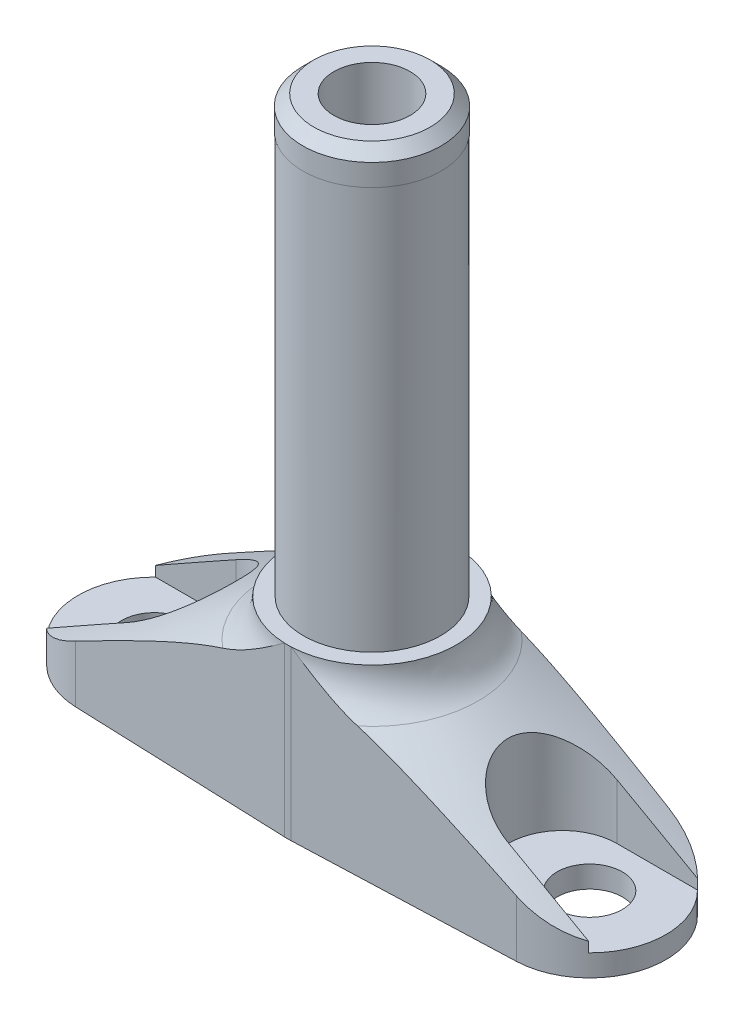
from build123d import *

# Parameters (mm, degrees)
SZKIC1_W                        = 27
SZKIC1_H                        = 25
ZAOKR_GLENIE1_R                 = 4
SZKIC4_R                        = 3
WYTNIJ_WYCI_GNI_CIE3_DEPTH      = 24.0000001
WYTNIJ_WYCI_GNI_CIE3_DEPTH_BACK = 3
WYTNIJ_WYCI_GNI_CIE2_DEPTH      = 24.0000001
SZKIC5_OUTSIDE_W                = 72.072
SZKIC5_OUTSIDE_H                = 72.072
WYTNIJ_WYCI_GNI_CIE4_DEPTH      = 26.0000001
SZKIC8_W                        = 7.75
SZKIC8_H                        = 9.576606241
SZKIC10_R                       = 3.5
WYTNIJ_WYCI_GNI_CIE5_DEPTH      = 56.423393859


with BuildPart() as part:
    # Szkic1 → Obrót1 (revolve)
    with BuildSketch(Plane.XY):
        with Locations((13.5, 12.5)):
            Rectangle(SZKIC1_W, SZKIC1_H)
    revolve(axis=Axis((0, 0, 0), (0, 1, 0)))

    # Szkic2 → Wycięcie-obrót1 (revolve, cut)
    with BuildSketch(Plane.XY):
        Polygon((27, 25), (27, 2), (7.75, 13.113992682), (7.75, 25), align=None)
    revolve(axis=Axis((0, 0, 0), (0, 1, 0)), mode=Mode.SUBTRACT)

    # Zaokrąglenie1
    zaokr_glenie1_edges = [part.edges().sort_by_distance(p)[0] for p in [
        (-7.75, 13.113992682, 0),
    ]]
    fillet(zaokr_glenie1_edges, radius=ZAOKR_GLENIE1_R)

    # Szkic4 → Wytnij-wyciągnięcie3 (cut, two sides)
    with BuildSketch(Plane(origin=(0, 2, 0), x_dir=(1, 0, 0), z_dir=(0, 1, 0))) as wytnij_wyci_gni_cie3_sk:
        with Locations((-20, 0)):
            Circle(SZKIC4_R)
        with Locations((20, 0)):
            Circle(SZKIC4_R)
    extrude(amount=WYTNIJ_WYCI_GNI_CIE3_DEPTH, mode=Mode.SUBTRACT)
    extrude(wytnij_wyci_gni_cie3_sk.sketch, amount=-WYTNIJ_WYCI_GNI_CIE3_DEPTH_BACK, mode=Mode.SUBTRACT)

    # Szkic3 → Wytnij-wyciągnięcie2 (cut, through all)
    with BuildSketch(Plane(origin=(0, 2, 0), x_dir=(1, 0, 0), z_dir=(0, 1, 0))):
        with BuildLine():
            Line((-17.5, 5), (-26.532998323, 5))
            ThreePointArc((-26.532998323, 5), (-27, 0), (-26.532998323, -5))
            Line((-26.532998323, -5), (-17.5, -5))
            ThreePointArc((-17.5, -5), (-12.5, 0), (-17.5, 5))
        make_face()
        with BuildLine():
            Line((17.5, 5), (26.532998323, 5))
            ThreePointArc((26.532998323, 5), (27, 0), (26.532998323, -5))
            Line((26.532998323, -5), (17.5, -5))
            ThreePointArc((17.5, -5), (12.5, 0), (17.5, 5))
        make_face()
    extrude(amount=WYTNIJ_WYCI_GNI_CIE2_DEPTH, mode=Mode.SUBTRACT)

    # Szkic5 outside → Wytnij-wyciągnięcie4 (cut, through all)
    with BuildSketch(Plane.XZ):
        Rectangle(SZKIC5_OUTSIDE_W, SZKIC5_OUTSIDE_H)
        with BuildLine():
            Line((-20.2625, 6.995076393), (-0.290625, 7.744548864))
            ThreePointArc((-0.290625, 7.744548864), (0, 7.75), (0.290625, 7.744548864))
            Line((0.290625, 7.744548864), (20.2625, 6.995076393))
            ThreePointArc((20.2625, 6.995076393), (27, 0), (20.2625, -6.995076393))
            Line((20.2625, -6.995076393), (0.290625, -7.744548864))
            ThreePointArc((0.290625, -7.744548864), (0, -7.75), (-0.290625, -7.744548864))
            Line((-0.290625, -7.744548864), (-20.2625, -6.995076393))
            ThreePointArc((-20.2625, -6.995076393), (-27, 0), (-20.2625, 6.995076393))
        make_face(mode=Mode.SUBTRACT)
    extrude(amount=-WYTNIJ_WYCI_GNI_CIE4_DEPTH, mode=Mode.SUBTRACT)

    # Szkic8 → Wycięcie-obrót2 (revolve, cut)
    with BuildSketch(Plane.XY):
        with Locations((3.875, 20.211696879)):
            Rectangle(SZKIC8_W, SZKIC8_H)
    revolve(axis=Axis((0, 25, 0), (0, -1, 0)), mode=Mode.SUBTRACT)

    # Szkic9 → Obrót2 (revolve)
    with BuildSketch(Plane.XY):
        Polygon((0, 15.423393759), (0, 55.423393759), (5.35, 55.423393759), (6.35, 54.423393759), (6.35, 52.423393759), (6.3, 52.423393759), (6.3, 15.423393759), align=None)
    revolve(axis=Axis((0, 15.423393759, 0), (0, 1, 0)))

    # Szkic10 → Wytnij-wyciągnięcie5 (cut, through all)
    with BuildSketch(Plane(origin=(0, 55.423393759, 0), x_dir=(1, 0, 0), z_dir=(0, 1, 0))):
        Circle(SZKIC10_R)
    extrude(amount=-WYTNIJ_WYCI_GNI_CIE5_DEPTH, mode=Mode.SUBTRACT)


solid = part.part
